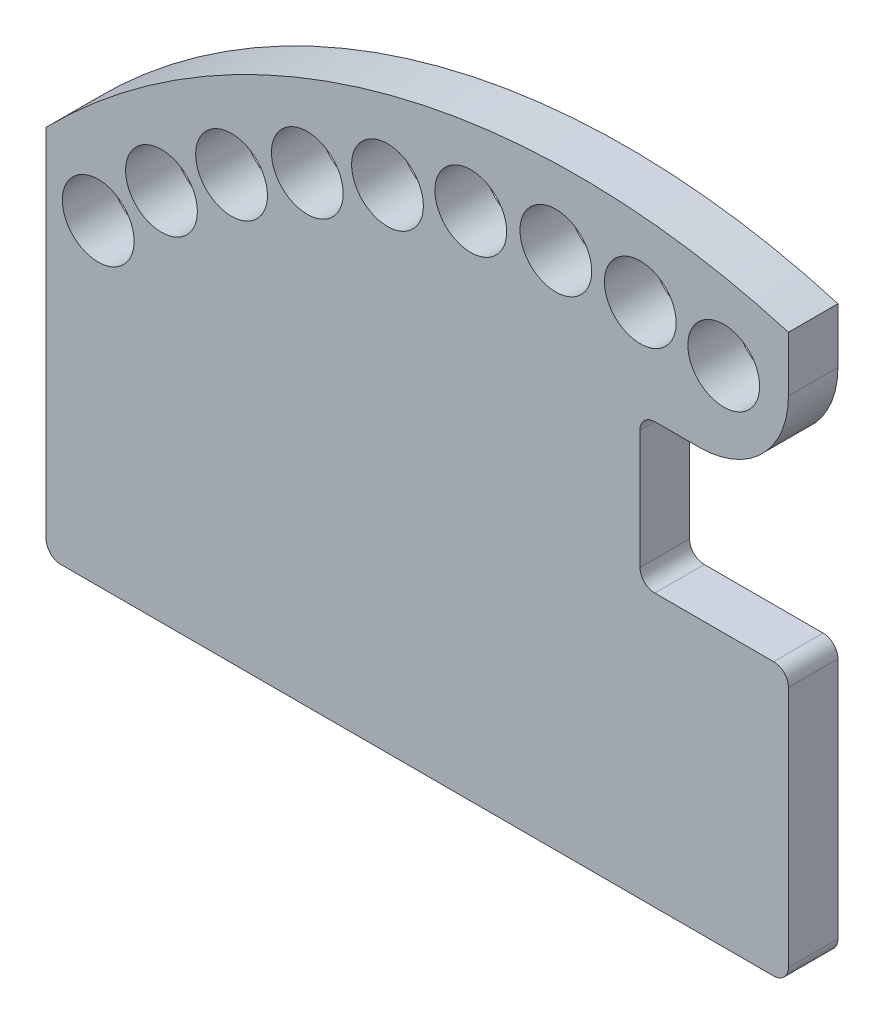
from build123d import *

# Parameters (mm, degrees)
BOSS_EXTRU_1_DEPTH           = 10
ESQUISSE2_R                  = 7.25
ENL_V_MAT_EXTRU_1_DEPTH      = 11
R_P_TITION_CIRCULAIRE1_COUNT = 7
R_P_TITION_CIRCULAIRE1_ANGLE = 44
R_P_TITION_CIRCULAIRE2_COUNT = 3
R_P_TITION_CIRCULAIRE2_ANGLE = 14.5
ESQUISSE5_W                  = 30
ESQUISSE5_H                  = 30
ENL_V_MAT_EXTRU_2_DEPTH      = 10
CONG_1_R                     = 18
CONG_2_R                     = 3


with BuildPart() as part:
    # Esquisse1 → Boss.-Extru.1 (new body)
    with BuildSketch(Plane.XY):
        with BuildLine():
            Line((75, 0), (-75, 0))
            Line((-75, 0), (-75, 75))
            ThreePointArc((-75, 75), (-5.436050989, 115.40325318), (75, 114.135353054))
            Line((75, 114.135353054), (75, 0))
        make_face()
    extrude(amount=BOSS_EXTRU_1_DEPTH)

    # Esquisse2 → Enlèv. mat.-Extru.1 (cut, through all)
    with BuildSketch(Plane.XY.offset(10)):
        with Locations((28, 104.924979155)):
            Circle(ESQUISSE2_R)
    enl_v_mat_extru_1 = extrude(amount=-ENL_V_MAT_EXTRU_1_DEPTH, mode=Mode.SUBTRACT)

    # Répétition circulaire1: Enlèv. mat.-Extru.1 ×7 about axis
    r_p_tition_circulaire1_axis = Axis((32.5, -30, 0), (0, 0, 1))
    for i in range(1, R_P_TITION_CIRCULAIRE1_COUNT):
        add(enl_v_mat_extru_1.rotate(r_p_tition_circulaire1_axis, i * R_P_TITION_CIRCULAIRE1_ANGLE / (R_P_TITION_CIRCULAIRE1_COUNT - 1)), mode=Mode.SUBTRACT)

    # Répétition circulaire2: Enlèv. mat.-Extru.1 ×3 about axis
    r_p_tition_circulaire2_axis = Axis((32.5, -30, 0), (0, 0, -1))
    for i in range(1, R_P_TITION_CIRCULAIRE2_COUNT):
        add(enl_v_mat_extru_1.rotate(r_p_tition_circulaire2_axis, i * R_P_TITION_CIRCULAIRE2_ANGLE / (R_P_TITION_CIRCULAIRE2_COUNT - 1)), mode=Mode.SUBTRACT)

    # Esquisse5 → Enlèv. mat.-Extru.2 (cut)
    with BuildSketch(Plane.XY.offset(10)):
        with Locations((60, 70)):
            Rectangle(ESQUISSE5_W, ESQUISSE5_H)
    extrude(amount=-ENL_V_MAT_EXTRU_2_DEPTH, mode=Mode.SUBTRACT)

    # Congé1
    cong_1_edges = [part.edges().sort_by_distance(p)[0] for p in [
        (75, 85, 5),
    ]]
    fillet(cong_1_edges, radius=CONG_1_R)

    # Congé2
    cong_2_edges = [part.edges().sort_by_distance(p)[0] for p in [
        (75, 55, 5),
        (45, 55, 5),
        (45, 85, 5),
        (75, 0, 5),
        (-75, 0, 5),
    ]]
    fillet(cong_2_edges, radius=CONG_2_R)


solid = part.part
